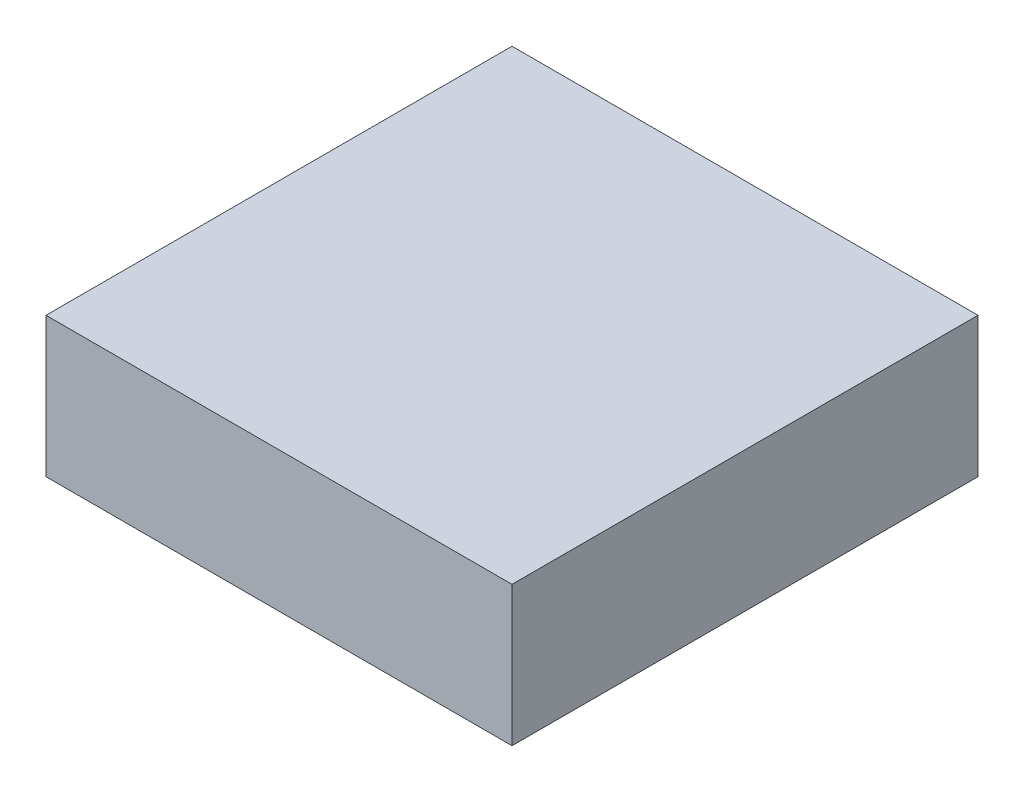
from build123d import *

# Parameters (mm, degrees)
SKETCH2_W           = 254
SKETCH2_H           = 254
BOSS_EXTRUDE2_DEPTH = 76.2


with BuildPart() as part:
    # Sketch2 → Boss-Extrude2 (new body)
    with BuildSketch(Plane(origin=(0, 0, 0), x_dir=(1, 0, 0), z_dir=(0, 1, 0))):
        Rectangle(SKETCH2_W, SKETCH2_H)
    extrude(amount=BOSS_EXTRUDE2_DEPTH)


solid = part.part
